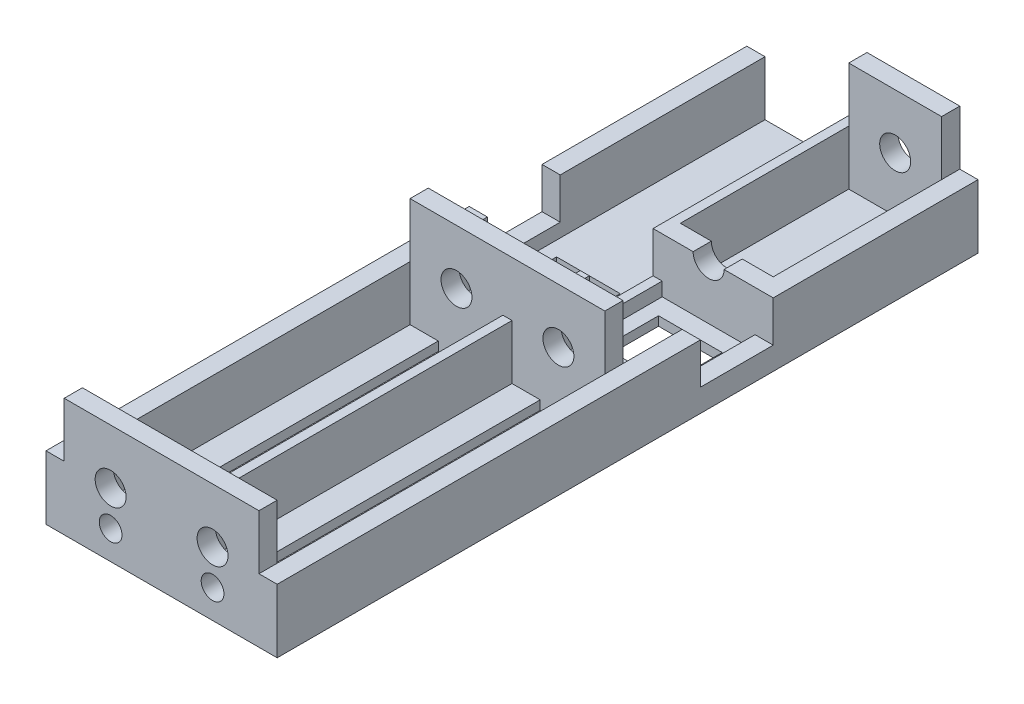
from build123d import *

# Parameters (mm, degrees)
GEARBOX_MOUNT_DEPTH  = 77
BOSS_EXTRUDE6_START  = 38
SKETCH7_R            = 1.7
SKETCH7_W            = 1
SKETCH7_H            = 6
BOSS_EXTRUDE6_DEPTH  = 1
BOSS_EXTRUDE7_START  = 76
SKETCH8_R            = 1.25
SKETCH8_R_2          = 1.7
SKETCH8_W            = 1
SKETCH8_H            = 6
BOSS_EXTRUDE7_DEPTH  = 1
CUT_EXTRUDE1_START   = 22.5
CUT_EXTRUDE1_DEPTH   = 8
BOSS_EXTRUDE9_START  = 22.5
BOSS_EXTRUDE9_DEPTH  = 2
SKETCH12_W           = 10.2
SKETCH12_H           = 12
SKETCH12_R           = 1.7
BOSS_EXTRUDE10_DEPTH = 2
CUT_EXTRUDE2_START   = 24.5
SKETCH9_W            = 7
SKETCH9_H            = 1
CUT_EXTRUDE2_DEPTH   = 6
CUT_EXTRUDE3_START   = 39
CUT_EXTRUDE3_DEPTH   = 36


with BuildPart() as part:
    # Sketch2 → Gearbox Mount (new body)
    with BuildSketch(Plane.XY):
        Polygon((-24.506477671, 70.636122542), (-24.506477671, 76.636122542), (-25.506477671, 76.636122542), (-25.506477671, 70.636122542), (-35.706477671, 70.636122542), (-35.706477671, 76.636122542), (-37.706477671, 76.636122542), (-37.706477671, 69.636122542), (-12.306477671, 69.636122542), (-12.306477671, 76.636122542), (-14.306477671, 76.636122542), (-14.306477671, 70.636122542), align=None)
    extrude(amount=GEARBOX_MOUNT_DEPTH)

    # Sketch7 → Boss-Extrude6 (add, symmetric)
    with BuildSketch(Plane.XY.offset(BOSS_EXTRUDE6_START)):
        Polygon((-24.506477671, 76.636122542), (-24.506477671, 70.636122542), (-14.306477671, 70.636122542), (-14.306477671, 76.636122542), (-14.306477671, 82.636122542), (-24.506477671, 82.636122542), align=None)
        with Locations((-19.406477671, 76.636122542)):
            Circle(SKETCH7_R, mode=Mode.SUBTRACT)
        with Locations((-25.006477671, 79.636122542)):
            Rectangle(SKETCH7_W, SKETCH7_H)
        Polygon((-25.506477671, 70.636122542), (-25.506477671, 76.636122542), (-25.506477671, 82.636122542), (-35.706477671, 82.636122542), (-35.706477671, 70.636122542), align=None)
        with Locations((-30.606477671, 76.636122542)):
            Circle(SKETCH7_R, mode=Mode.SUBTRACT)
    extrude(amount=BOSS_EXTRUDE6_DEPTH, both=True)

    # Sketch8 → Boss-Extrude7 (add, symmetric)
    with BuildSketch(Plane.XY.offset(BOSS_EXTRUDE7_START)):
        Polygon((-35.706477671, 82.636122542), (-35.706477671, 70.636122542), (-25.506477671, 70.636122542), (-25.506477671, 76.636122542), (-25.506477671, 82.636122542), align=None)
        with Locations((-30.606477671, 72.786122542)):
            Circle(SKETCH8_R, mode=Mode.SUBTRACT)
        with Locations((-30.606477671, 76.636122542)):
            Circle(SKETCH8_R_2, mode=Mode.SUBTRACT)
        with Locations((-25.006477671, 79.636122542)):
            Rectangle(SKETCH8_W, SKETCH8_H)
        Polygon((-14.306477671, 82.636122542), (-24.506477671, 82.636122542), (-24.506477671, 76.636122542), (-24.506477671, 70.636122542), (-14.306477671, 70.636122542), (-14.306477671, 76.636122542), align=None)
        with Locations((-19.406477671, 72.786122542)):
            Circle(SKETCH8_R, mode=Mode.SUBTRACT)
        with Locations((-19.406477671, 76.636122542)):
            Circle(SKETCH8_R_2, mode=Mode.SUBTRACT)
    extrude(amount=BOSS_EXTRUDE7_DEPTH, both=True)

    # Sketch10 → Cut-Extrude1 (cut)
    with BuildSketch(Plane.XY.offset(CUT_EXTRUDE1_START)):
        Polygon((-14.306477671, 70.636122542), (-14.306477671, 72.136122542), (-12.306477671, 72.136122542), (-12.306477671, 82.636122542), (-37.706477671, 82.636122542), (-37.706477671, 72.136122542), (-35.706477671, 72.136122542), (-35.706477671, 70.636122542), (-25.506477671, 70.636122542), (-25.506477671, 72.136122542), (-24.506477671, 72.136122542), (-24.506477671, 70.636122542), align=None)
    extrude(amount=CUT_EXTRUDE1_DEPTH, mode=Mode.SUBTRACT)

    # Sketch11 → Boss-Extrude9 (add)
    with BuildSketch(Plane.XY.offset(BOSS_EXTRUDE9_START)):
        with BuildLine():
            Line((-24.506477671, 76.636122542), (-24.506477671, 70.636122542))
            Line((-24.506477671, 70.636122542), (-14.306477671, 70.636122542))
            Line((-14.306477671, 70.636122542), (-14.306477671, 76.636122542))
            Line((-14.306477671, 76.636122542), (-17.706477671, 76.636122542))
            ThreePointArc((-17.706477671, 76.636122542), (-19.406477671, 74.936122542), (-21.106477671, 76.636122542))
            Line((-21.106477671, 76.636122542), (-24.506477671, 76.636122542))
        make_face()
    extrude(amount=-BOSS_EXTRUDE9_DEPTH)

    # Sketch12 → Boss-Extrude10 (add)
    with BuildSketch(Plane.XY):
        with Locations((-19.406477671, 76.636122542)):
            Rectangle(SKETCH12_W, SKETCH12_H)
        with Locations((-19.406477671, 76.636122542)):
            Circle(SKETCH12_R, mode=Mode.SUBTRACT)
    extrude(amount=BOSS_EXTRUDE10_DEPTH)

    # Sketch9 → Cut-Extrude2 (cut)
    with BuildSketch(Plane.XY.offset(CUT_EXTRUDE2_START)):
        with Locations((-30.606477671, 70.136122542)):
            Rectangle(SKETCH9_W, SKETCH9_H)
        with Locations((-19.406477671, 70.136122542)):
            Rectangle(SKETCH9_W, SKETCH9_H)
    extrude(amount=CUT_EXTRUDE2_DEPTH, mode=Mode.SUBTRACT)

    # Sketch13 → Cut-Extrude3 (cut)
    with BuildSketch(Plane.XY.offset(CUT_EXTRUDE3_START)):
        Polygon((-19.406477671, 69.636122542), (-21.406477671, 69.636122542), (-21.406477671, 70.636122542), (-17.406477671, 70.636122542), (-17.406477671, 69.636122542), align=None)
        Polygon((-30.606477671, 69.636122542), (-32.606477671, 69.636122542), (-32.606477671, 70.636122542), (-28.606477671, 70.636122542), (-28.606477671, 69.636122542), align=None)
    extrude(amount=CUT_EXTRUDE3_DEPTH, mode=Mode.SUBTRACT)


solid = part.part
